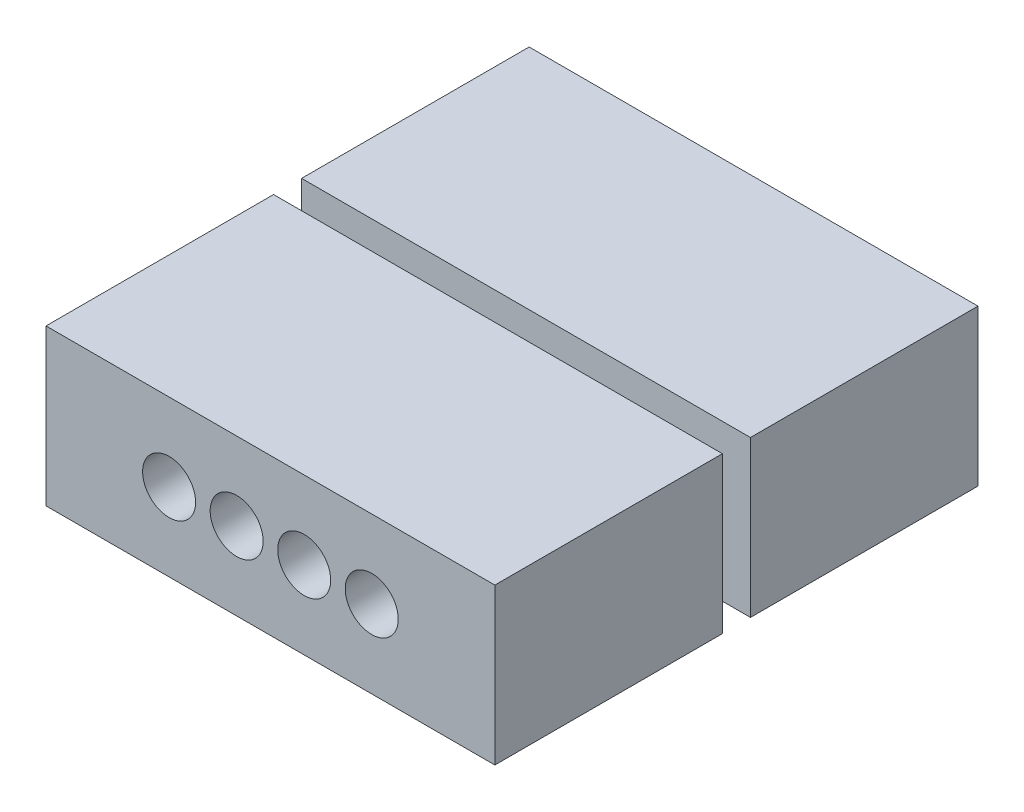
from build123d import *

# Parameters (mm, degrees)
BOSS_EXTRUDE1_DEPTH   = 5
SKETCH2_W             = 12.4
SKETCH2_H             = 0.9
CUT_EXTRUDE1_DEPTH    = 1.5
CROQUIS1_R            = 0.85
CORTAR_EXTRUIR1_DEPTH = 3
CROQUIS2_W            = 9.4
CROQUIS2_H            = 1.2
CORTAR_EXTRUIR2_DEPTH = 7.5


with BuildPart() as part:
    # Sketch1 → Boss-Extrude1 (new body)
    with BuildSketch(Plane(origin=(0, 0, 0), x_dir=(1, 0, 0), z_dir=(0, 1, 0))):
        Polygon((-7.2, -7.75), (7.2, -7.75), (7.2, -0.45), (6.2, -0.45), (6.2, 0.45), (7.2, 0.45), (7.2, 7.75), (-7.2, 7.75), (-7.2, 0.45), (-6.2, 0.45), (-6.2, -0.45), (-7.2, -0.45), align=None)
    extrude(amount=BOSS_EXTRUDE1_DEPTH)

    # Sketch2 → Cut-Extrude1 (cut)
    with BuildSketch(Plane(origin=(0, 5, 0), x_dir=(1, 0, 0), z_dir=(0, 1, 0))):
        Rectangle(SKETCH2_W, SKETCH2_H)
    extrude(amount=-CUT_EXTRUDE1_DEPTH, mode=Mode.SUBTRACT)

    # Croquis1 → Cortar-Extruir1 (cut)
    with BuildSketch(Plane.XY.offset(7.75)):
        with Locations((-3.25, 2.5)):
            Circle(CROQUIS1_R)
        with Locations((-1.083333333, 2.5)):
            Circle(CROQUIS1_R)
        with Locations((1.083333333, 2.5)):
            Circle(CROQUIS1_R)
        with Locations((3.25, 2.5)):
            Circle(CROQUIS1_R)
    extrude(amount=-CORTAR_EXTRUIR1_DEPTH, mode=Mode.SUBTRACT)

    # Croquis2 → Cortar-Extruir2 (cut)
    with BuildSketch(Plane(origin=(0, 0, -7.75), x_dir=(-1, 0, 0), z_dir=(0, 0, -1))):
        with Locations((0, 2.6)):
            Rectangle(CROQUIS2_W, CROQUIS2_H)
    extrude(amount=-CORTAR_EXTRUIR2_DEPTH, mode=Mode.SUBTRACT)


solid = part.part
